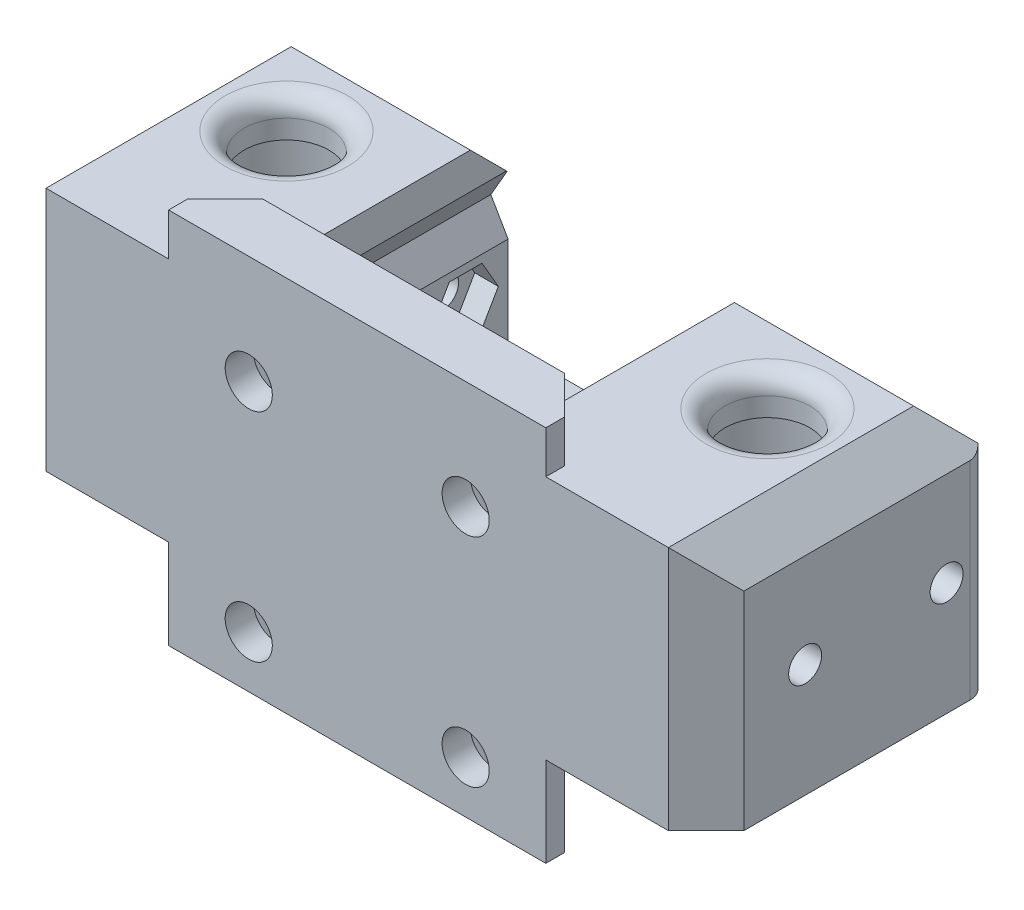
from build123d import *

# Parameters (mm, degrees)
ESQUISSE1_W                  = 20
ESQUISSE1_H                  = 40
BOSS_EXTRU_1_DEPTH           = 6
ESQUISSE2_W                  = 37
ESQUISSE2_H                  = 30
BOSS_EXTRU_2_DEPTH           = 6
ESQUISSE3_W                  = 23
ESQUISSE3_H                  = 30
BOSS_EXTRU_3_DEPTH           = 20
ESQUISSE4_R                  = 9.25
ENL_V_MAT_EXTRU_1_DEPTH      = 8
ESQUISSE5_R                  = 8.25
ENL_V_MAT_EXTRU_2_DEPTH      = 14
ESQUISSE6_R                  = 4.5
ENL_V_MAT_EXTRU_3_DEPTH      = 4
ESQUISSE9_R                  = 1.75
ENL_V_MAT_EXTRU_5_DEPTH      = 23
ENL_V_MAT_EXTRU_7_DEPTH      = 2.5
CHANFREIN1_SIZE              = 4
CONG_2_R                     = 2
ESQUISSE10_R                 = 2.5
ENL_V_MAT_EXTRU_6_DEPTH      = 31
ENL_V_MAT_EXTRU_8_DEPTH      = 25
ENL_V_MAT_EXTRU_8_DEPTH_BACK = 3


with BuildPart() as part:
    # Esquisse1 → Boss.-Extru.1 (new body)
    with BuildSketch(Plane.XY):
        with Locations((-10, 0)):
            Rectangle(ESQUISSE1_W, ESQUISSE1_H)
    extrude(amount=BOSS_EXTRU_1_DEPTH)

    # Esquisse2 → Boss.-Extru.2 (add)
    with BuildSketch(Plane(origin=(0, -10.5, 0), x_dir=(-1, 0, 0), z_dir=(0, -1, 0))):
        with Locations((1.5, 9)):
            Rectangle(ESQUISSE2_W, ESQUISSE2_H)
    extrude(amount=-BOSS_EXTRU_2_DEPTH)

    # Esquisse3 → Boss.-Extru.3 (add)
    with BuildSketch(Plane(origin=(0, -4.5, 0), x_dir=(1, 0, 0), z_dir=(0, 1, 0))):
        with Locations((5.5, 9)):
            Rectangle(ESQUISSE3_W, ESQUISSE3_H)
    extrude(amount=BOSS_EXTRU_3_DEPTH)

    # Esquisse4 → Enlèv. mat.-Extru.1 (cut)
    with BuildSketch(Plane(origin=(0, -10.5, 0), x_dir=(-1, 0, 0), z_dir=(0, -1, 0))):
        with Locations((-5.5, 12)):
            Circle(ESQUISSE4_R)
    extrude(amount=-ENL_V_MAT_EXTRU_1_DEPTH, mode=Mode.SUBTRACT)

    # Esquisse5 → Enlèv. mat.-Extru.2 (cut)
    with BuildSketch(Plane(origin=(0, -2.5, 0), x_dir=(-1, 0, 0), z_dir=(0, -1, 0))):
        with Locations((-5.5, 12)):
            Circle(ESQUISSE5_R)
    extrude(amount=-ENL_V_MAT_EXTRU_2_DEPTH, mode=Mode.SUBTRACT)

    # Esquisse6 → Enlèv. mat.-Extru.3 (cut)
    with BuildSketch(Plane(origin=(0, 11.5, 0), x_dir=(-1, 0, 0), z_dir=(0, -1, 0))):
        with Locations((-5.5, 12)):
            Circle(ESQUISSE6_R)
    extrude(amount=-ENL_V_MAT_EXTRU_3_DEPTH, mode=Mode.SUBTRACT)

    # Esquisse9 → Enlèv. mat.-Extru.5 (cut)
    with BuildSketch(Plane(origin=(17, 0, 0), x_dir=(0, 0, -1), z_dir=(1, 0, 0))):
        with Locations((4.5, 1.5)):
            Circle(ESQUISSE9_R)
        with Locations((19.5, 1.5)):
            Circle(ESQUISSE9_R)
    extrude(amount=-ENL_V_MAT_EXTRU_5_DEPTH, mode=Mode.SUBTRACT)

    # Esquisse11 → Enlèv. mat.-Extru.7 (cut)
    with BuildSketch(Plane.ZY.offset(6)):
        Polygon((-17.767949192, -1.5), (-16.035898385, 1.5), (-17.767949192, 4.5), (-21.232050808, 4.5), (-22.964101615, 1.5), (-21.232050808, -1.5), align=None)
        Polygon((-2.767949192, -1.5), (-1.035898385, 1.5), (-2.767949192, 4.5), (-6.232050808, 4.5), (-7.964101615, 1.5), (-6.232050808, -1.5), align=None)
    extrude(amount=-ENL_V_MAT_EXTRU_7_DEPTH, mode=Mode.SUBTRACT)

    # Chanfrein1
    chanfrein1_edges = [part.edges().sort_by_distance(p)[0] for p in [
        (17, 2.5, 6),
        (0, 17.75, 0),
        (17, 15.5, -9),
        (5.5, 15.5, -24),
        (0, -15.25, 0),
    ]]
    chamfer(chanfrein1_edges, length=CHANFREIN1_SIZE)

    # Congé2
    cong_2_edges = [part.edges().sort_by_distance(p)[0] for p in [
        (17, 0.5, -24),
        (10, 15.5, -12),
    ]]
    fillet(cong_2_edges, radius=CONG_2_R)

    # Symétrie1: part across plane


with BuildPart() as part_1:
    add(part.part)
    add(part.part.mirror(Plane(origin=(-20, 20, 6), x_dir=(0, 0, 1), z_dir=(1, 0, 0))))

    # Esquisse10 → Enlèv. mat.-Extru.6 (cut, through all)
    with BuildSketch(Plane.XY.offset(6)):
        with Locations((-31.5, 8.5)):
            Circle(ESQUISSE10_R)
        with Locations((-8.5, 8.5)):
            Circle(ESQUISSE10_R)
        with Locations((-8.5, -14.5)):
            Circle(ESQUISSE10_R)
        with Locations((-31.5, -14.5)):
            Circle(ESQUISSE10_R)
    extrude(amount=-ENL_V_MAT_EXTRU_6_DEPTH, mode=Mode.SUBTRACT)

    # Esquisse12 → Enlèv. mat.-Extru.8 (cut, two sides)
    with BuildSketch(Plane(origin=(0, 0, 0), x_dir=(-1, 0, 0), z_dir=(0, 0, -1))) as enl_v_mat_extru_8_sk:
        Polygon((10.665063509, 4.75), (12.830127019, 8.5), (10.665063509, 12.25), (6.334936491, 12.25), (4.169872981, 8.5), (6.334936491, 4.75), align=None)
        Polygon((33.665063509, 4.75), (35.830127019, 8.5), (33.665063509, 12.25), (29.334936491, 12.25), (27.169872981, 8.5), (29.334936491, 4.75), align=None)
        Polygon((10.665063509, -18.25), (12.830127019, -14.5), (10.665063509, -10.75), (6.334936491, -10.75), (4.169872981, -14.5), (6.334936491, -18.25), align=None)
        Polygon((33.665063509, -18.25), (35.830127019, -14.5), (33.665063509, -10.75), (29.334936491, -10.75), (27.169872981, -14.5), (29.334936491, -18.25), align=None)
    extrude(amount=ENL_V_MAT_EXTRU_8_DEPTH, mode=Mode.SUBTRACT)
    extrude(enl_v_mat_extru_8_sk.sketch, amount=-ENL_V_MAT_EXTRU_8_DEPTH_BACK, mode=Mode.SUBTRACT)


solid = part_1.part
